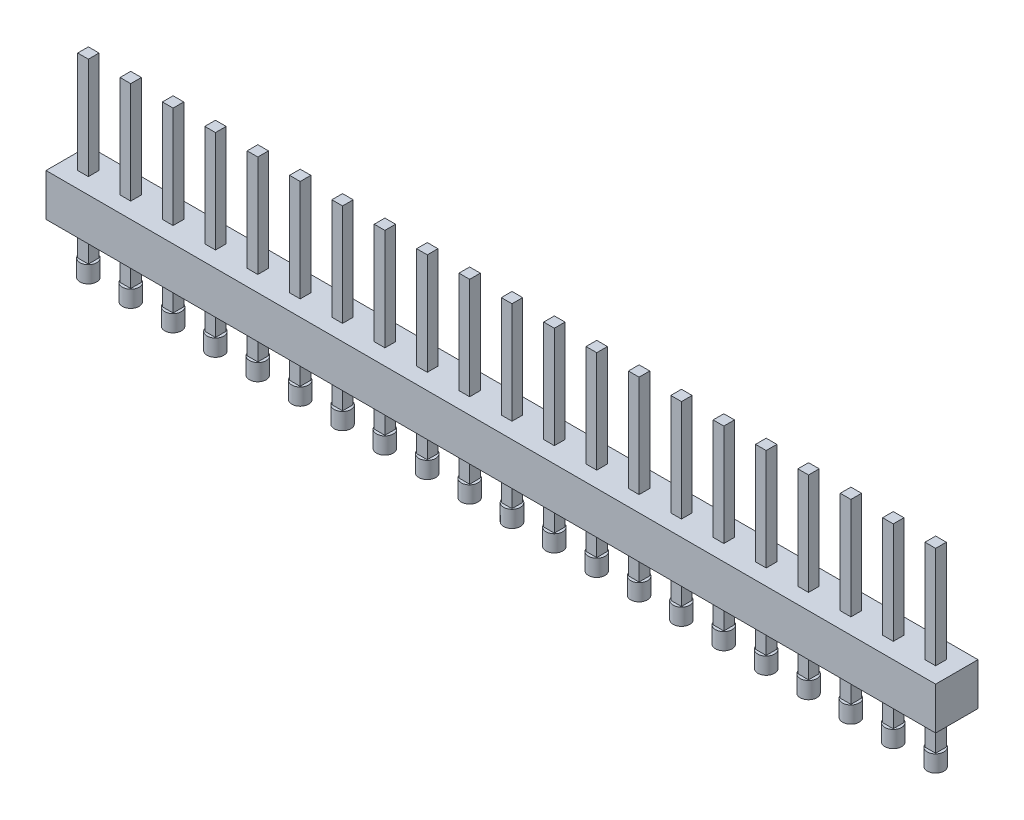
from build123d import *

# Parameters (mm, degrees)
SKETCH1_W           = 2.54
SKETCH1_H           = 2.54
BOSS_EXTRUDE1_DEPTH = 2.54
BOSS_EXTRUDE2_START = -5.54
SKETCH2_W           = 0.64
SKETCH2_H           = 0.64
BOSS_EXTRUDE2_DEPTH = 11.64
SKETCH3_R           = 0.5
BOSS_EXTRUDE3_DEPTH = 1
LPATTERN1_COUNT     = 21
LPATTERN1_PITCH     = 2.54


with BuildPart() as part:
    # Sketch1 → Boss-Extrude1 (new body)
    with BuildSketch(Plane(origin=(0, 0, 0), x_dir=(1, 0, 0), z_dir=(0, 1, 0))):
        with Locations((1.27, 1.27)):
            Rectangle(SKETCH1_W, SKETCH1_H)
    boss_extrude1 = extrude(amount=BOSS_EXTRUDE1_DEPTH)

    # Sketch2 → Boss-Extrude2 (add)
    with BuildSketch(Plane(origin=(0, 2.54, 0), x_dir=(1, 0, 0), z_dir=(0, 1, 0)).offset(BOSS_EXTRUDE2_START)):
        with Locations((1.27, 1.27)):
            Rectangle(SKETCH2_W, SKETCH2_H)
    boss_extrude2 = extrude(amount=BOSS_EXTRUDE2_DEPTH)

    # Sketch3 → Boss-Extrude3 (add)
    with BuildSketch(Plane.XZ.offset(3)):
        with Locations((1.27, -1.27)):
            Circle(SKETCH3_R)
    boss_extrude3 = extrude(amount=-BOSS_EXTRUDE3_DEPTH)

    # LPattern1: Boss-Extrude1, Boss-Extrude2, Boss-Extrude3 ×21
    with Locations(*[(i * LPATTERN1_PITCH, 0, 0) for i in range(1, LPATTERN1_COUNT)]):
        add(boss_extrude1)
        add(boss_extrude2)
        add(boss_extrude3)


solid = part.part
